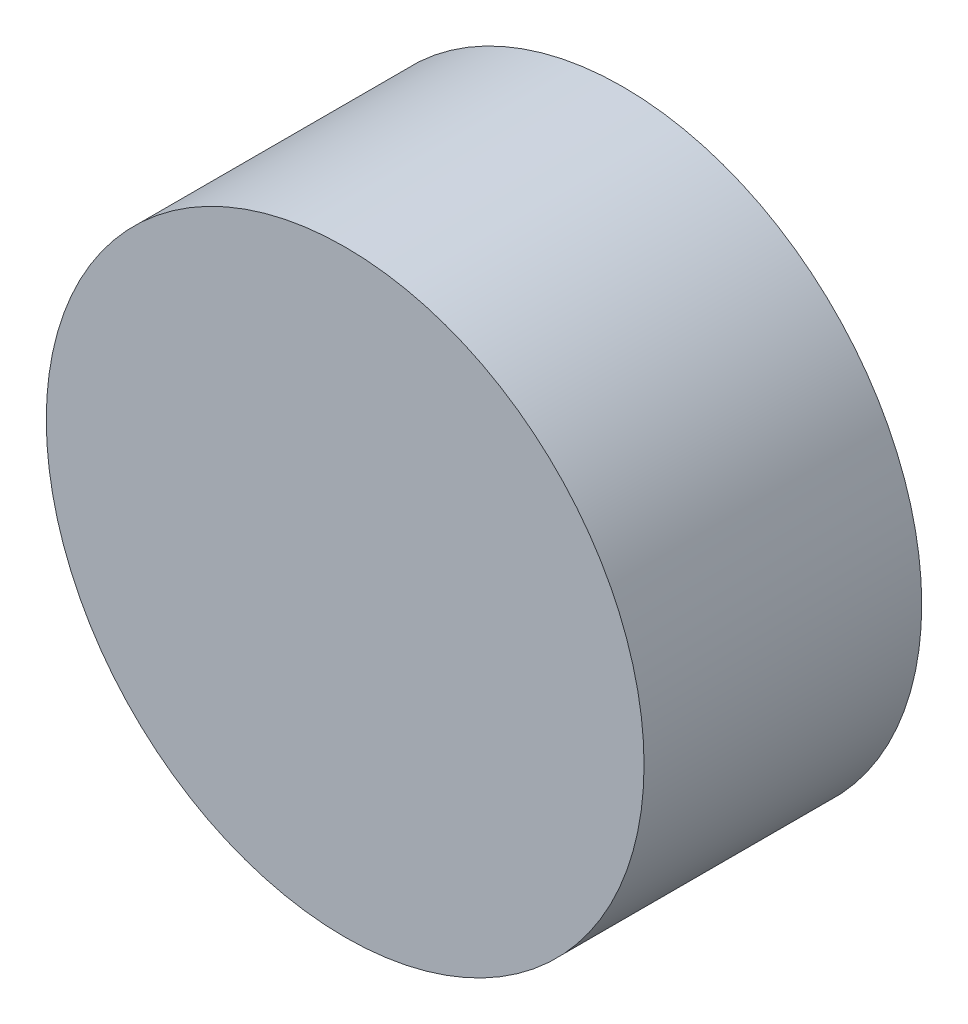
from build123d import *

# Parameters (mm, degrees)
SKETCH1_R           = 30.7594
BOSS_EXTRUDE1_DEPTH = 28.575


with BuildPart() as part:
    # Sketch1 → Boss-Extrude1 (new body)
    with BuildSketch(Plane.XY):
        Circle(SKETCH1_R)
    extrude(amount=BOSS_EXTRUDE1_DEPTH)


solid = part.part
